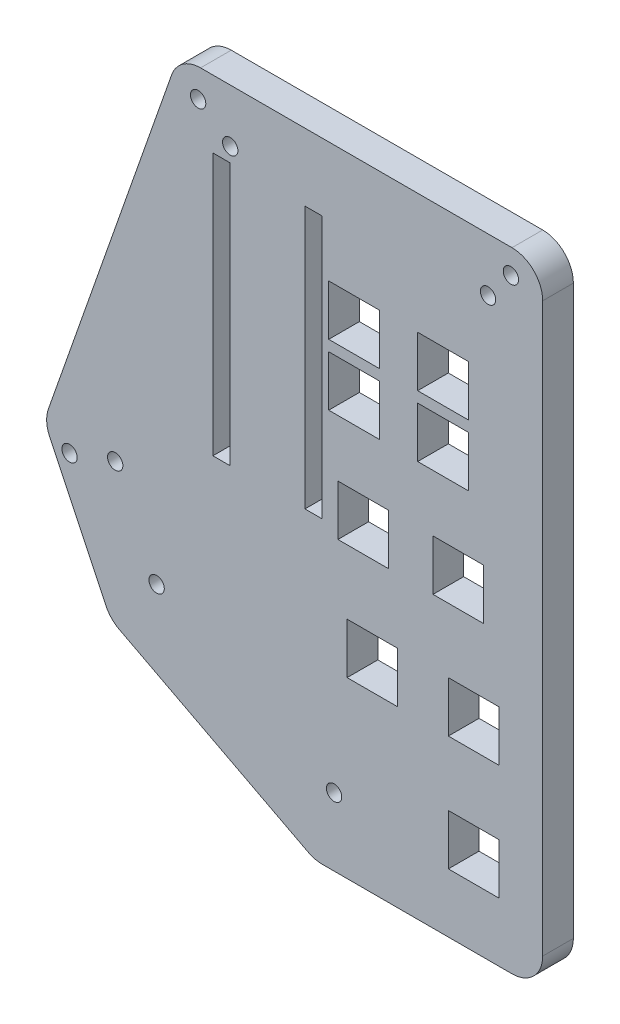
from build123d import *

# Parameters (mm, degrees)
SKETCH1_R           = 1.27
BOSS_EXTRUDE1_DEPTH = 5.08
SKETCH5_W           = 8.382
SKETCH5_H           = 8.382
SKETCH5_W_2         = 2.794
SKETCH5_H_2         = 43.434
CUT_EXTRUDE1_DEPTH  = 6.08
SKETCH7_R           = 1.27
CUT_EXTRUDE3_DEPTH  = 6.08


with BuildPart() as part:
    # Sketch1 → Boss-Extrude1 (new body)
    with BuildSketch(Plane.XY):
        with BuildLine():
            Line((-3.314058103, 6.35), (48.26, 6.35))
            ThreePointArc((48.26, 6.35), (51.852102448, 4.862102448), (53.34, 1.27))
            Line((53.34, 1.27), (53.34, -92.71))
            ThreePointArc((53.34, -92.71), (51.852102448, -96.302102448), (48.26, -97.79))
            Line((48.26, -97.79), (16.846989059, -97.79))
            ThreePointArc((16.846989059, -97.79), (15.638688158, -97.644208035), (14.499741809, -97.215200367))
            Line((14.499741809, -97.215200367), (-16.7505185, -80.933552139))
            ThreePointArc((-16.7505185, -80.933552139), (-18.059258376, -79.955412607), (-18.989802686, -78.61241436))
            Line((-18.989802686, -78.61241436), (-28.309569459, -59.040904135))
            ThreePointArc((-28.309569459, -59.040904135), (-28.795802898, -57.127870198), (-28.51617555, -55.173917704))
            Line((-28.51617555, -55.173917704), (-8.107195629, 2.952923842))
            ThreePointArc((-8.107195629, 2.952923842), (-6.251501454, 5.414614163), (-3.314058103, 6.35))
        make_face()
        with Locations((48.0822, 2.286)):
            Circle(SKETCH1_R, mode=Mode.SUBTRACT)
        with Locations((-3.718687848, 1.651)):
            Circle(SKETCH1_R, mode=Mode.SUBTRACT)
        with Locations((-25.012261453, -59.761967182)):
            Circle(SKETCH1_R, mode=Mode.SUBTRACT)
    extrude(amount=BOSS_EXTRUDE1_DEPTH)

    # Sketch5 → Cut-Extrude1 (cut, through all)
    with BuildSketch(Plane(origin=(0, 0, 0), x_dir=(-1, 0, 0), z_dir=(0, 0, -1))):
        with Locations((-36.83, -17.78)):
            Rectangle(SKETCH5_W, SKETCH5_H)
        with Locations((-39.37, -45.72)):
            Rectangle(SKETCH5_W, SKETCH5_H)
        with Locations((-36.83, -27.94)):
            Rectangle(SKETCH5_W, SKETCH5_H)
        with Locations((-41.91, -64.77)):
            Rectangle(SKETCH5_W, SKETCH5_H)
        with Locations((-41.91, -83.82)):
            Rectangle(SKETCH5_W, SKETCH5_H)
        with Locations((-22.098, -17.78)):
            Rectangle(SKETCH5_W, SKETCH5_H)
        with Locations((-22.098, -27.94)):
            Rectangle(SKETCH5_W, SKETCH5_H)
        with Locations((-23.622, -45.72)):
            Rectangle(SKETCH5_W, SKETCH5_H)
        with Locations((-25.146, -64.77)):
            Rectangle(SKETCH5_W, SKETCH5_H)
        with Locations((-15.367, -26.543)):
            Rectangle(SKETCH5_W_2, SKETCH5_H_2)
        with Locations((-0.127, -26.543)):
            Rectangle(SKETCH5_W_2, SKETCH5_H_2)
    extrude(amount=-CUT_EXTRUDE1_DEPTH, mode=Mode.SUBTRACT)

    # Sketch7 → Cut-Extrude3 (cut, through all)
    with BuildSketch(Plane.XY.offset(5.08)):
        with Locations((44.2976, -2.4892)):
            Circle(SKETCH7_R)
        with Locations((1.6002, -2.4384)):
            Circle(SKETCH7_R)
        with Locations((-17.4498, -57.15)):
            Circle(SKETCH7_R)
        with Locations((-10.5918, -71.3486)):
            Circle(SKETCH7_R)
        with Locations((18.796, -86.5378)):
            Circle(SKETCH7_R)
    extrude(amount=-CUT_EXTRUDE3_DEPTH, mode=Mode.SUBTRACT)


solid = part.part
